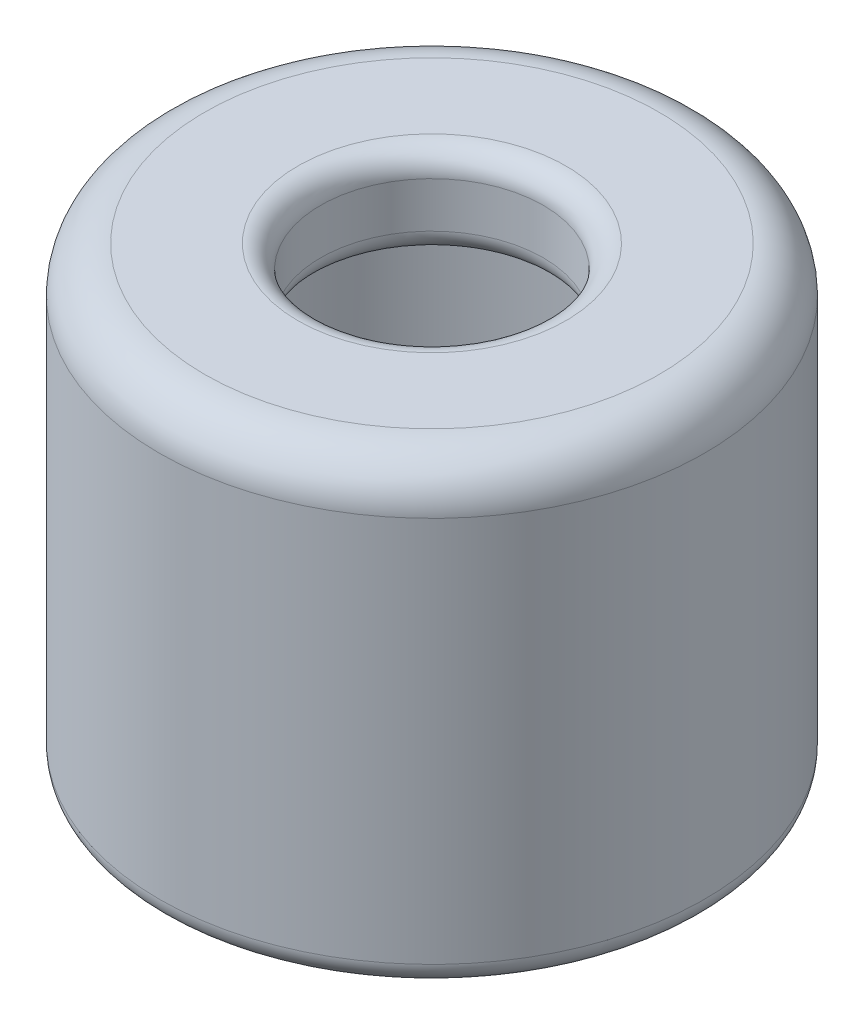
from build123d import *

# Parameters (mm, degrees)
SKETCH_5_R          = 6
SKETCH_5_R_2        = 2.45
EXTRUDE_1_DEPTH     = 10
SKETCH_7_R          = 4.5
CUT_EXTRUDE_1_DEPTH = 8
FILLET_1_R          = 1
FILLET_2_R          = 0.5


with BuildPart() as part:
    # 草图5 → 凸台-拉伸1 (new body)
    with BuildSketch(Plane(origin=(0, 0, 0), x_dir=(1, 0, 0), z_dir=(0, 1, 0))):
        Circle(SKETCH_5_R)
        Circle(SKETCH_5_R_2, mode=Mode.SUBTRACT)
    extrude(amount=EXTRUDE_1_DEPTH)

    # 草图7 → 切除-拉伸1 (cut)
    with BuildSketch(Plane.XZ):
        Circle(SKETCH_7_R)
    extrude(amount=-CUT_EXTRUDE_1_DEPTH, mode=Mode.SUBTRACT)

    # 圆角1
    fillet_1_edges = [part.edges().sort_by_distance(p)[0] for p in [
        (-6, 10, 0),
    ]]
    fillet(fillet_1_edges, radius=FILLET_1_R)

    # 圆角2
    fillet_2_edges = [part.edges().sort_by_distance(p)[0] for p in [
        (-4.5, 8, 0),
        (-2.45, 8, 0),
        (-4.5, 0, 0),
        (-6, 0, 0),
        (-2.45, 10, 0),
    ]]
    fillet(fillet_2_edges, radius=FILLET_2_R)


solid = part.part
